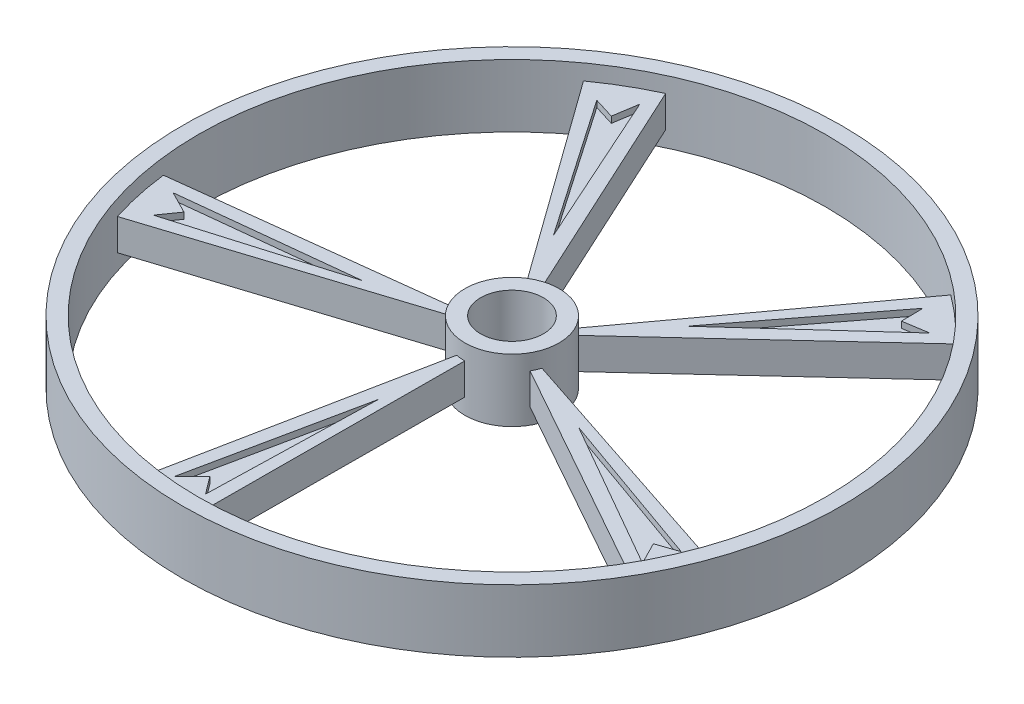
from build123d import *

# Parameters (mm, degrees)
SKETCH_1_R                      = 75
SKETCH_1_R_2                    = 50
EXTRUDE_1_DEPTH                 = 50
SKETCH_2_R                      = 525
SKETCH_2_R_2                    = 500
EXTRUDE_2_DEPTH                 = 50
EXTRUDE_4_DEPTH                 = 25
CUT_EXTRUDE_1_DEPTH             = 10
PATTERN_CIRCULAR_1_COUNT        = 5
PATTERN_CIRCULAR_1_COPY_1_DEPTH = 10
PATTERN_CIRCULAR_1_COPY_2_DEPTH = 10
PATTERN_CIRCULAR_1_COPY_3_DEPTH = 10
PATTERN_CIRCULAR_1_COPY_4_DEPTH = 10


with BuildPart() as part:
    # 草图1 → 凸台-拉伸1 (new body, symmetric)
    with BuildSketch(Plane(origin=(0, 0, 0), x_dir=(1, 0, 0), z_dir=(0, 1, 0))):
        Circle(SKETCH_1_R)
        Circle(SKETCH_1_R_2, mode=Mode.SUBTRACT)
    extrude(amount=EXTRUDE_1_DEPTH, both=True)



with BuildPart() as body_2:
    # 草图2 → 凸台-拉伸2 (new body, symmetric)
    with BuildSketch(Plane(origin=(0, 0, 0), x_dir=(1, 0, 0), z_dir=(0, 1, 0))):
        Circle(SKETCH_2_R)
        Circle(SKETCH_2_R_2, mode=Mode.SUBTRACT)
    extrude(amount=EXTRUDE_2_DEPTH, both=True)


with BuildPart() as part_1:
    add(part.part)

    add(body_2.part)  # 凸台-拉伸4 merges body 2
    # 草图3 → 凸台-拉伸4 (add, symmetric)
    with BuildSketch(Plane(origin=(0, 0, 0), x_dir=(1, 0, 0), z_dir=(0, 1, 0))):
        with BuildLine():
            Line((487.740991927, -160.966827682), (47.481076098, -15.669952538))
            ThreePointArc((47.481076098, -15.669952538), (45.762156741, -20.145098917), (43.622562007, -24.435058502))
            Line((43.622562007, -24.435058502), (449.989958214, -252.06064129))
            Line((449.989958214, -252.06064129), (487.740991927, -160.966827682))
        make_face()
        with BuildLine():
            ThreePointArc((-0.230551046, -49.999468459), (-5.017843464, -49.747575287), (-9.759008616, -49.038370189))
            Line((-9.759008616, -49.038370189), (-100.669371014, -505.856903799))
            Line((-100.669371014, -505.856903799), (-2.368295015, -513.610733921))
            Line((-2.368295015, -513.610733921), (-0.230551046, -49.999468459))
        make_face()
        with BuildLine():
            ThreePointArc((-47.623564481, -15.231418389), (-48.863354552, -10.600593468), (-49.653961028, -5.872321028))
            Line((-49.653961028, -5.872321028), (-512.207051127, -60.576118701))
            Line((-512.207051127, -60.576118701), (-489.204678742, -156.462062868))
            Line((-489.204678742, -156.462062868), (-47.623564481, -15.231418389))
        make_face()
        with BuildLine():
            ThreePointArc((-29.202430469, 40.585934198), (-25.181370454, 43.196048223), (-20.928826975, 45.409076201))
            Line((-20.928826975, 45.409076201), (-215.89199586, 468.418803535))
            Line((-215.89199586, 468.418803535), (-299.976823903, 416.911861118))
            Line((-299.976823903, 416.911861118), (-29.202430469, 40.585934198))
        make_face()
        with BuildLine():
            ThreePointArc((29.575469897, 40.314905189), (33.300411729, 37.29721945), (36.719234612, 33.936673518))
            Line((36.719234612, 33.936673518), (378.778459787, 350.074860255))
            Line((378.778459787, 350.074860255), (303.808805733, 414.127763353))
            Line((303.808805733, 414.127763353), (29.575469897, 40.314905189))
        make_face()
    extrude(amount=EXTRUDE_4_DEPTH, both=True)

    # 草图4 → 切除-拉伸1 (cut)
    with BuildSketch(Plane.XZ.offset(25)):
        Polygon((-72.052388825, 465.166723777), (-44.040818004, 437.155152956), (-23.032139887, 465.166723777), (-16.029247182, 197.055974487), align=None)
    cut_extrude_1 = extrude(amount=-CUT_EXTRUDE_1_DEPTH, mode=Mode.SUBTRACT)

    # 镜向1: 切除-拉伸1 across plane
    add(cut_extrude_1.mirror(Plane.ZX), mode=Mode.SUBTRACT)

    # 阵列(圆周)1: 切除-拉伸1 ×5 about axis
    pattern_circular_1_axis = Axis((0, 0, 0), (0, 1, 0))
    for i in range(1, PATTERN_CIRCULAR_1_COUNT):
        add(cut_extrude_1.rotate(pattern_circular_1_axis, i * 360 / PATTERN_CIRCULAR_1_COUNT), mode=Mode.SUBTRACT)

    # 阵列(圆周)1 copy 1 sketch → 阵列(圆周)1 copy 1 (cut)
    with BuildSketch(Plane(origin=(0, 25, 0), x_dir=(0.309016994, 0, -0.951056516), z_dir=(0, 1, 0))):
        Polygon((-72.052388825, -465.166723777), (-44.040818004, -437.155152956), (-23.032139887, -465.166723777), (-16.029247182, -197.055974487), align=None)
    extrude(amount=-PATTERN_CIRCULAR_1_COPY_1_DEPTH, mode=Mode.SUBTRACT)

    # 阵列(圆周)1 copy 2 sketch → 阵列(圆周)1 copy 2 (cut)
    with BuildSketch(Plane(origin=(0, 25, 0), x_dir=(-0.809016994, 0, -0.587785252), z_dir=(0, 1, 0))):
        Polygon((-72.052388825, -465.166723777), (-44.040818004, -437.155152956), (-23.032139887, -465.166723777), (-16.029247182, -197.055974487), align=None)
    extrude(amount=-PATTERN_CIRCULAR_1_COPY_2_DEPTH, mode=Mode.SUBTRACT)

    # 阵列(圆周)1 copy 3 sketch → 阵列(圆周)1 copy 3 (cut)
    with BuildSketch(Plane(origin=(0, 25, 0), x_dir=(-0.809016994, 0, 0.587785252), z_dir=(0, 1, 0))):
        Polygon((-72.052388825, -465.166723777), (-44.040818004, -437.155152956), (-23.032139887, -465.166723777), (-16.029247182, -197.055974487), align=None)
    extrude(amount=-PATTERN_CIRCULAR_1_COPY_3_DEPTH, mode=Mode.SUBTRACT)

    # 阵列(圆周)1 copy 4 sketch → 阵列(圆周)1 copy 4 (cut)
    with BuildSketch(Plane(origin=(0, 25, 0), x_dir=(0.309016994, 0, 0.951056516), z_dir=(0, 1, 0))):
        Polygon((-72.052388825, -465.166723777), (-44.040818004, -437.155152956), (-23.032139887, -465.166723777), (-16.029247182, -197.055974487), align=None)
    extrude(amount=-PATTERN_CIRCULAR_1_COPY_4_DEPTH, mode=Mode.SUBTRACT)


solid = part_1.part
